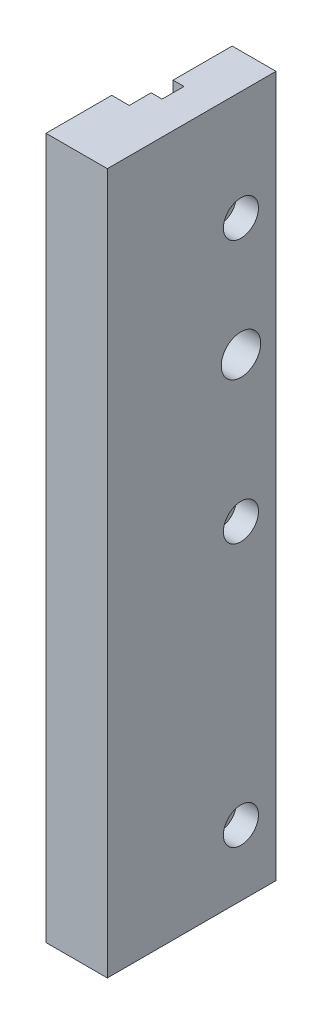
from build123d import *

# Parameters (mm, degrees)
BOSS_EXTRUDE1_DEPTH = 160
SKETCH2_R           = 4
SKETCH2_R_2         = 4.5
CUT_EXTRUDE2_DEPTH  = 5
SKETCH3_R           = 2.5
SKETCH3_R_2         = 4.5
CUT_EXTRUDE3_DEPTH  = 10


with BuildPart() as part:
    # Sketch1 → Boss-Extrude1 (new body)
    with BuildSketch(Plane(origin=(0, 0, 0), x_dir=(1, 0, 0), z_dir=(0, 1, 0))):
        Polygon((0, 20), (2.5, 20), (2.5, 25), (0, 25), (0, 38.5), (10, 38.5), (10, 0), (0, 0), (-4, 0), (-4, 15), (0, 15), align=None)
    extrude(amount=BOSS_EXTRUDE1_DEPTH)

    # Sketch2 → Cut-Extrude2 (cut)
    with BuildSketch(Plane(origin=(10, 0, 0), x_dir=(0, 0, -1), z_dir=(1, 0, 0))):
        with Locations((30.5, 15)):
            Circle(SKETCH2_R)
        with Locations((30.5, 135)):
            Circle(SKETCH2_R)
        with Locations((30.5, 75)):
            Circle(SKETCH2_R)
        with Locations((30.5, 108)):
            Circle(SKETCH2_R_2)
    extrude(amount=-CUT_EXTRUDE2_DEPTH, mode=Mode.SUBTRACT)

    # Sketch3 → Cut-Extrude3 (cut, through all)
    with BuildSketch(Plane(origin=(5, 0, 0), x_dir=(0, 0, -1), z_dir=(1, 0, 0))):
        with Locations((30.5, 15)):
            Circle(SKETCH3_R)
        with Locations((30.5, 135)):
            Circle(SKETCH3_R)
        with Locations((30.5, 75)):
            Circle(SKETCH3_R)
        with Locations((30.5, 108)):
            Circle(SKETCH3_R_2)
    extrude(amount=-CUT_EXTRUDE3_DEPTH, mode=Mode.SUBTRACT)


solid = part.part
